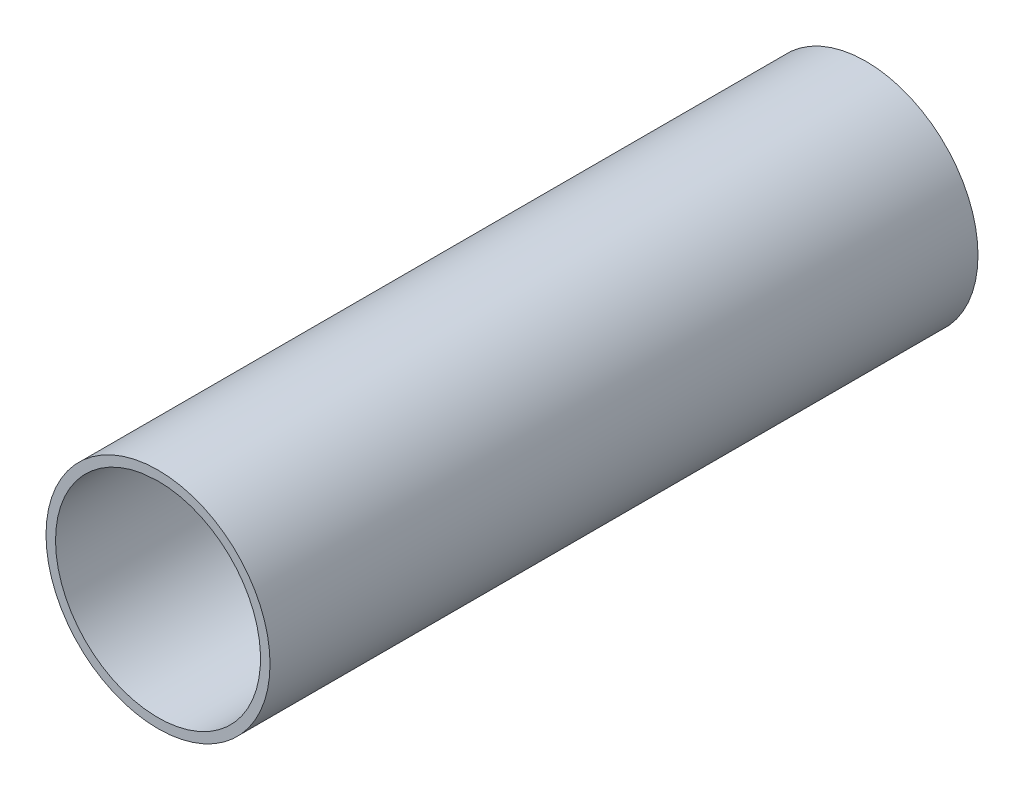
from build123d import *

# Parameters (mm, degrees)
SKETCH_2_R          = 20
SKETCH_2_R_2        = 18.3
EXTRUDE_1_DEPTH     = 126.4
SKETCH_5_R          = 3
EXTRUDE_3_DEPTH     = 126.4
CUT_EXTRUDE1_DEPTH  = 59
CUT_EXTRUDE2_DEPTH  = 59
SKETCH3_R           = 3
BOSS_EXTRUDE6_DEPTH = 58.6


with BuildPart() as part:
    # Эскиз2 → Бобышка-Вытянуть1 (new body)
    with BuildSketch(Plane.XY):
        Circle(SKETCH_2_R)
        Circle(SKETCH_2_R_2, mode=Mode.SUBTRACT)
    extrude(amount=EXTRUDE_1_DEPTH)

    # Эскиз5 → Бобышка-Вытянуть3 (add, through all)
    with BuildSketch(Plane(origin=(0, 0, 0), x_dir=(-1, 0, 0), z_dir=(0, 0, -1))):
        with BuildLine():
            Line((0, 18.3), (0, 9.219544457))
            ThreePointArc((0, 9.219544457), (-0.725705562, 6.35915669), (-2.727272727, 4.190702026))
            ThreePointArc((-2.727272727, 4.190702026), (-0.409836066, -4.983175132), (3.375314281, 3.688801093))
            ThreePointArc((3.375314281, 3.688801093), (1.754930846, 6.155139323), (1.506314907, 9.095659151))
            Line((1.506314907, 9.095659151), (2.989905079, 18.054098361))
            ThreePointArc((2.989905079, 18.054098361), (1.5, 18.238420984), (0, 18.3))
        make_face()
        Circle(SKETCH_5_R, mode=Mode.SUBTRACT)
    extrude(amount=-EXTRUDE_3_DEPTH)

    # Sketch1 → Cut-Extrude1 (cut)
    with BuildSketch(Plane(origin=(0, 0, 0), x_dir=(-1, 0, 0), z_dir=(0, 0, -1))):
        with BuildLine():
            Line((0, 18.3), (2.989905079, 18.054098361))
            ThreePointArc((2.989905079, 18.054098361), (-1.5, -18.238420984), (0, 18.3))
        make_face()
    extrude(amount=-CUT_EXTRUDE1_DEPTH, mode=Mode.SUBTRACT)

    # Sketch2 → Cut-Extrude2 (cut)
    with BuildSketch(Plane.XY.offset(126.4)):
        with BuildLine():
            Line((0, 18.3), (-2.989905079, 18.054098361))
            ThreePointArc((-2.989905079, 18.054098361), (1.5, -18.238420984), (0, 18.3))
        make_face()
    extrude(amount=-CUT_EXTRUDE2_DEPTH, mode=Mode.SUBTRACT)


with BuildPart() as body_2:
    # Sketch3 → Boss-Extrude6 (new body)
    with BuildSketch(Plane.XY):
        with BuildLine():
            Line((5, 0), (5, 16.561702811))
            ThreePointArc((5, 16.561702811), (0, 17.3), (-5, 16.561702811))
            Line((-5, 16.561702811), (-5, 0))
            ThreePointArc((-5, 0), (0, -5), (5, 0))
        make_face()
        Circle(SKETCH3_R, mode=Mode.SUBTRACT)
    extrude(amount=BOSS_EXTRUDE6_DEPTH)


solid = Compound([part.part, body_2.part])
